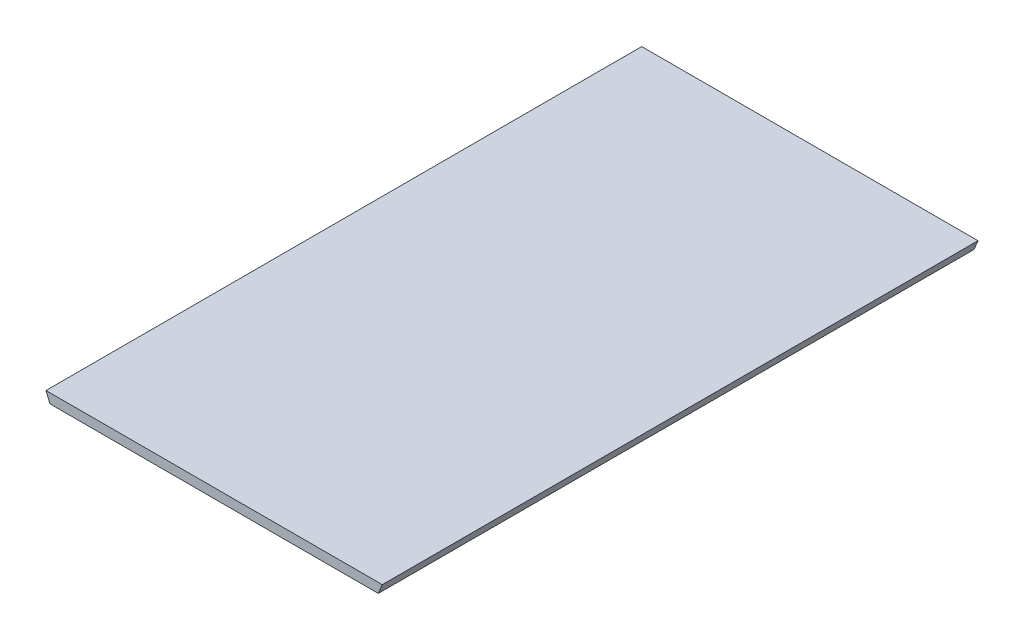
from build123d import *

# Parameters (mm, degrees)
ESQUISSE1_W        = 170.86
ESQUISSE1_H        = 310
BOSS_EXTRU_1_DEPTH = 5
BOSS_EXTRU_2_DEPTH = 310


with BuildPart() as part:
    # Esquisse1 → Boss.-Extru.1 (new body)
    with BuildSketch(Plane(origin=(0, 0, 0), x_dir=(1, 0, 0), z_dir=(0, 1, 0))):
        with Locations((85.43, 155)):
            Rectangle(ESQUISSE1_W, ESQUISSE1_H)
    extrude(amount=BOSS_EXTRU_1_DEPTH)

    # Esquisse3 → Boss.-Extru.2 (add)
    with BuildSketch(Plane(origin=(0, 0, -310), x_dir=(-1, 0, 0), z_dir=(0, 0, -1))):
        Polygon((2.07, 5), (-172.93, 5), (-170.86, 0), (0, 0), align=None)
    extrude(amount=-BOSS_EXTRU_2_DEPTH)


solid = part.part
